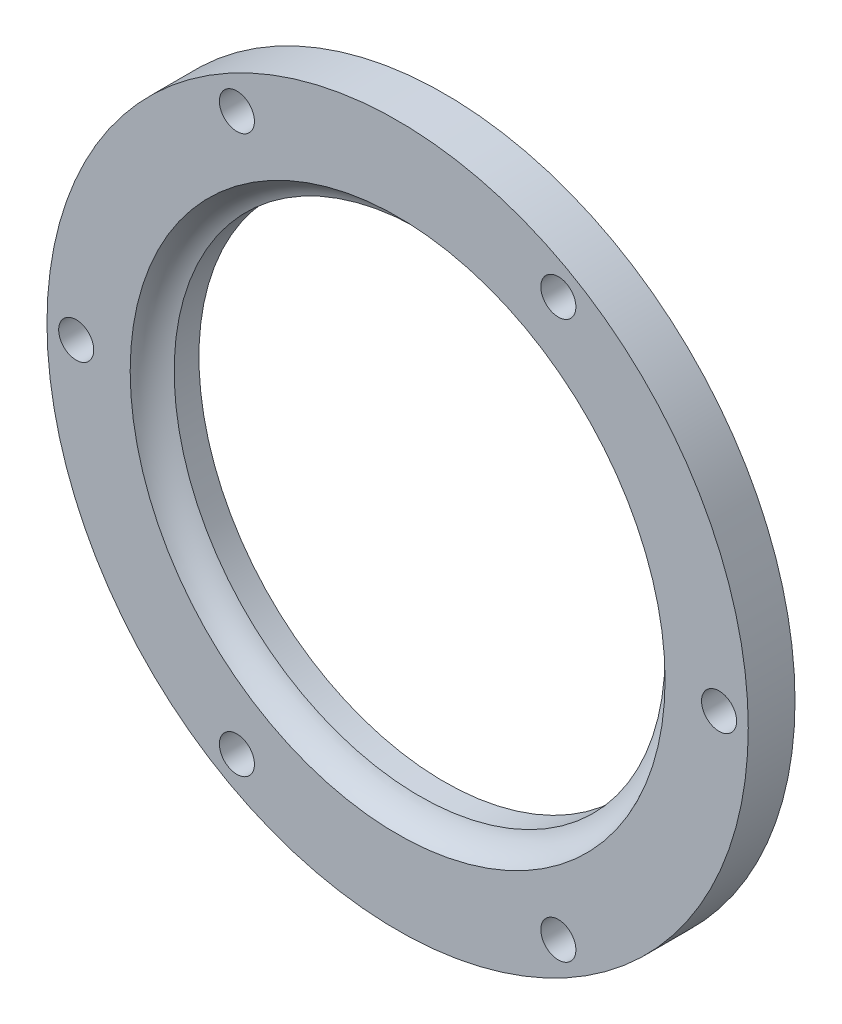
from build123d import *

# Parameters (mm, degrees)
SCHIZZO1_R                   = 30
SCHIZZO1_R_2                 = 21
ESTRUSIONE_ESTRUSIONE1_DEPTH = 4
SCHIZZO2_R                   = 3.05
SCHIZZO3_R                   = 1.5
TAGLIO_ESTRUSIONE1_DEPTH     = 10
RIPETIZIONECIRCOLARE1_COUNT  = 6


with BuildPart() as part:
    # Schizzo1 → Estrusione-Estrusione1 (new body)
    with BuildSketch(Plane.XY):
        Circle(SCHIZZO1_R)
        Circle(SCHIZZO1_R_2, mode=Mode.SUBTRACT)
    extrude(amount=ESTRUSIONE_ESTRUSIONE1_DEPTH)

    # Schizzo2 → Taglia-Rivoluzione1 (revolve, cut)
    with BuildSketch(Plane(origin=(0, 0, 0), x_dir=(0, 0, -1), z_dir=(1, 0, 0))):
        with Locations((-5, 20)):
            Circle(SCHIZZO2_R)
    revolve(axis=Axis((0, 0, 4), (0, 0, -1)), mode=Mode.SUBTRACT)

    # Schizzo3 → Taglio-Estrusione1 (cut)
    with BuildSketch(Plane.XY):
        with Locations((-27.5, 0)):
            Circle(SCHIZZO3_R)
    taglio_estrusione1 = extrude(amount=TAGLIO_ESTRUSIONE1_DEPTH, mode=Mode.SUBTRACT)

    # RipetizioneCircolare1: Taglio-Estrusione1 ×6 about axis
    ripetizionecircolare1_axis = Axis((0, 0, 0), (0, 0, 1))
    for i in range(1, RIPETIZIONECIRCOLARE1_COUNT):
        add(taglio_estrusione1.rotate(ripetizionecircolare1_axis, i * 360 / RIPETIZIONECIRCOLARE1_COUNT), mode=Mode.SUBTRACT)


solid = part.part
